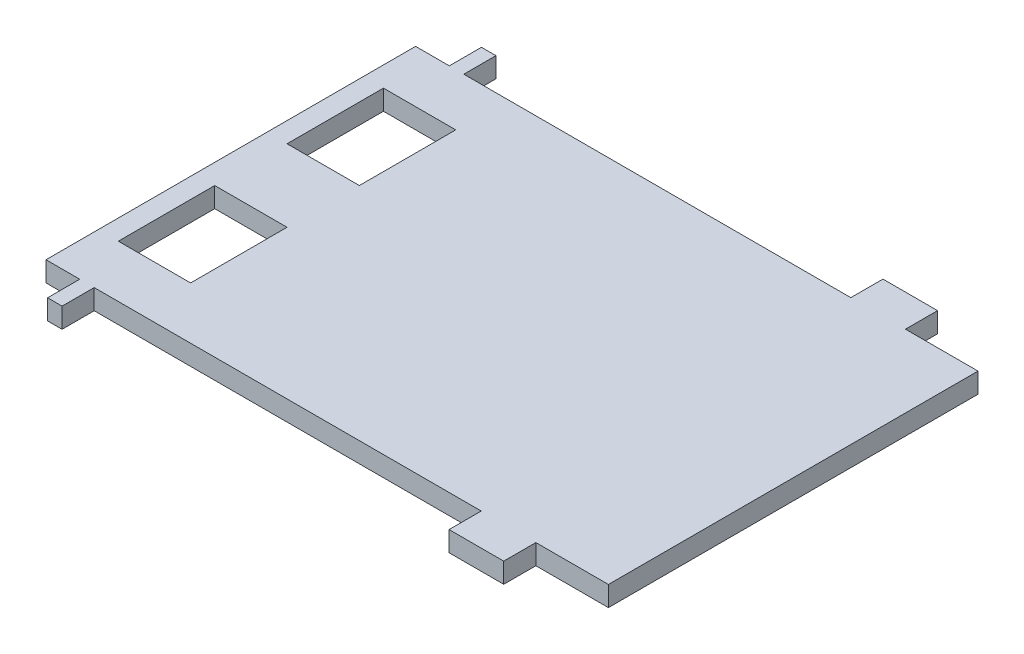
from build123d import *

# Parameters (mm, degrees)
SKETCH_1_W          = 70
SKETCH_1_H          = 54
EXTRUDE_1_DEPTH     = 2.5
SKETCH_2_W          = 9.03
SKETCH_2_H          = 4
SKETCH_2_W_2        = 48.17
SKETCH_2_W_3        = 4.2
CUT_EXTRUDE_1_DEPTH = 3.5
SKETCH_3_W          = 9
SKETCH_3_H          = 12
CUT_EXTRUDE_2_DEPTH = 3.5


with BuildPart() as part:
    # 草图1 → 凸台-拉伸1 (new body)
    with BuildSketch(Plane(origin=(0, 0, 0), x_dir=(1, 0, 0), z_dir=(0, 1, 0))):
        Rectangle(SKETCH_1_W, SKETCH_1_H)
    extrude(amount=EXTRUDE_1_DEPTH)

    # 草图2 → 切除-拉伸1 (cut, through all)
    with BuildSketch(Plane(origin=(0, 2.5, 0), x_dir=(1, 0, 0), z_dir=(0, 1, 0))):
        with Locations((30.485, 25)):
            Rectangle(SKETCH_2_W, SKETCH_2_H)
        with Locations((-4.915, 25)):
            Rectangle(SKETCH_2_W_2, SKETCH_2_H)
        with Locations((-32.9, 25)):
            Rectangle(SKETCH_2_W_3, SKETCH_2_H)
        with Locations((-32.9, -25)):
            Rectangle(SKETCH_2_W_3, SKETCH_2_H)
        with Locations((30.485, -25)):
            Rectangle(SKETCH_2_W, SKETCH_2_H)
        with Locations((-4.915, -25)):
            Rectangle(SKETCH_2_W_2, SKETCH_2_H)
    extrude(amount=-CUT_EXTRUDE_1_DEPTH, mode=Mode.SUBTRACT)

    # 草图3 → 切除-拉伸2 (cut, through all)
    with BuildSketch(Plane(origin=(0, 2.5, 0), x_dir=(1, 0, 0), z_dir=(0, 1, 0))):
        with Locations((-28, 10.5)):
            Rectangle(SKETCH_3_W, SKETCH_3_H)
        with Locations((-28, -10.5)):
            Rectangle(SKETCH_3_W, SKETCH_3_H)
    extrude(amount=-CUT_EXTRUDE_2_DEPTH, mode=Mode.SUBTRACT)


solid = part.part
